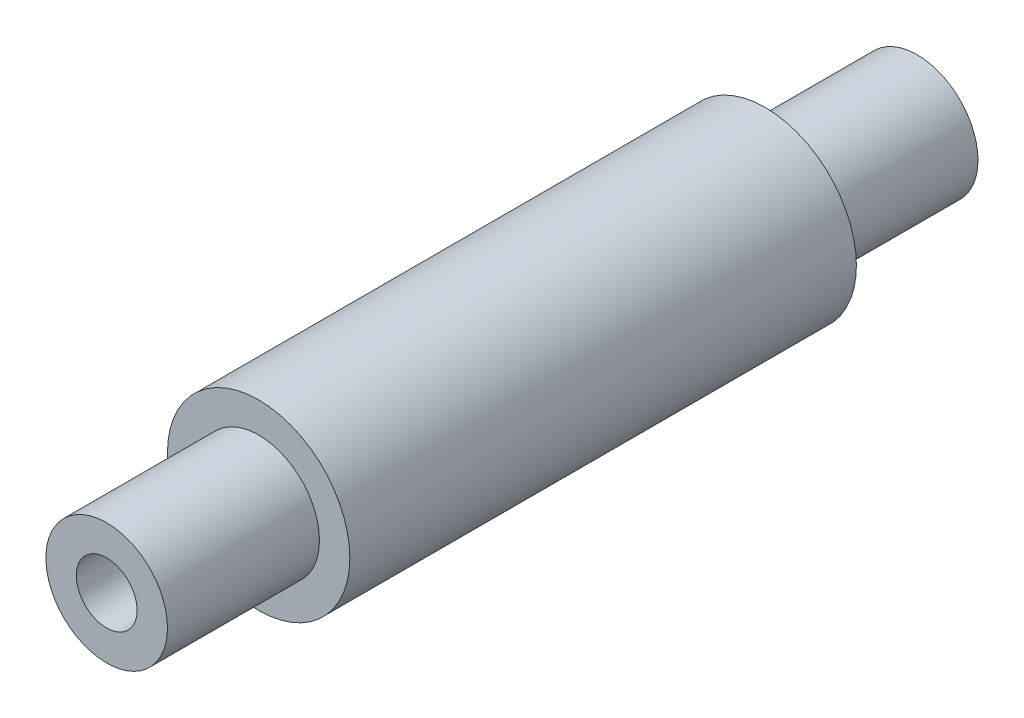
from build123d import *

# Parameters (mm, degrees)
SKETCH1_R           = 6
BOSS_EXTRUDE1_DEPTH = 40
SKETCH2_R           = 9
BOSS_EXTRUDE2_DEPTH = 25
SKETCH4_R           = 3
CUT_EXTRUDE1_DEPTH  = 45
SKETCH6_R           = 3
CUT_EXTRUDE2_DEPTH  = 10


with BuildPart() as part:
    # Sketch1 → Boss-Extrude1 (new body, symmetric)
    with BuildSketch(Plane.XY):
        Circle(SKETCH1_R)
    extrude(amount=BOSS_EXTRUDE1_DEPTH, both=True)

    # Sketch2 → Boss-Extrude2 (add, symmetric)
    with BuildSketch(Plane.XY):
        Circle(SKETCH2_R)
    extrude(amount=BOSS_EXTRUDE2_DEPTH, both=True)

    # Sketch4 → Cut-Extrude1 (cut)
    with BuildSketch(Plane.XY.offset(40)):
        Circle(SKETCH4_R)
    extrude(amount=-CUT_EXTRUDE1_DEPTH, mode=Mode.SUBTRACT)

    # Sketch6 → Cut-Extrude2 (cut, through all)
    with BuildSketch(Plane(origin=(0, 0, 0), x_dir=(0, 0, -1), z_dir=(1, 0, 0))):
        Circle(SKETCH6_R)
    extrude(amount=-CUT_EXTRUDE2_DEPTH, mode=Mode.SUBTRACT)


solid = part.part
